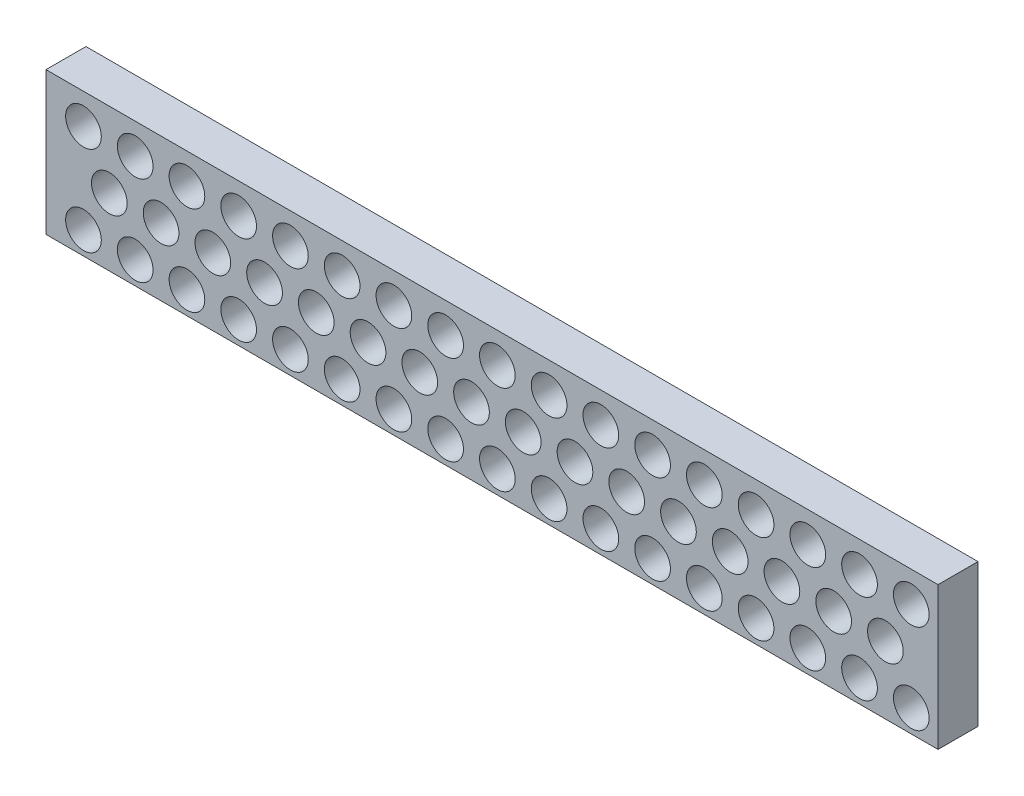
from build123d import *

# Parameters (mm, degrees)
SKETCH1_W               = 635
SKETCH1_H               = 101.6
BOSS_EXTRUDE1_DEPTH     = 28.448
SKETCH1_3_R             = 12.7
CUT_EXTRUDE1_DEPTH      = 601.604588248
LPATTERN1_COUNT         = 16
LPATTERN1_PITCH         = 36.83
CUT_EXTRUDE2_DEPTH      = 601.604588248
CUT_EXTRUDE2_DEPTH_BACK = 601.604588248
SKETCH3_R               = 12.7


with BuildPart() as part:
    # Sketch1 → Boss-Extrude1 (new body)
    with BuildSketch(Plane.XY):
        with Locations((-280.035, 2.75844)):
            Rectangle(SKETCH1_W, SKETCH1_H)
    extrude(amount=-BOSS_EXTRUDE1_DEPTH)

    # Sketch1_3 → Cut-Extrude1 (cut, symmetric)
    with BuildSketch(Plane.XY):
        Circle(SKETCH1_3_R)
        with Locations((18.415, 31.89478)):
            Circle(SKETCH1_3_R)
        with Locations((18.415, -31.89478)):
            Circle(SKETCH1_3_R)
    cut_extrude1 = extrude(amount=CUT_EXTRUDE1_DEPTH, both=True, mode=Mode.SUBTRACT)

    # LPattern1: Cut-Extrude1 ×16
    with Locations(*[(-i * LPATTERN1_PITCH, 0, 0) for i in range(1, LPATTERN1_COUNT)]):
        add(cut_extrude1, mode=Mode.SUBTRACT)

    # Sketch3 → Cut-Extrude2 (cut, two sides: drawn at the far end of the back side and taken through both)
    with BuildSketch(Plane.XY.offset(-CUT_EXTRUDE2_DEPTH_BACK)):
        with Locations((-570.865, 31.89478)):
            Circle(SKETCH3_R)
        with Locations((-570.865, -31.89478)):
            Circle(SKETCH3_R)
    extrude(amount=CUT_EXTRUDE2_DEPTH + CUT_EXTRUDE2_DEPTH_BACK, mode=Mode.SUBTRACT)


solid = part.part
